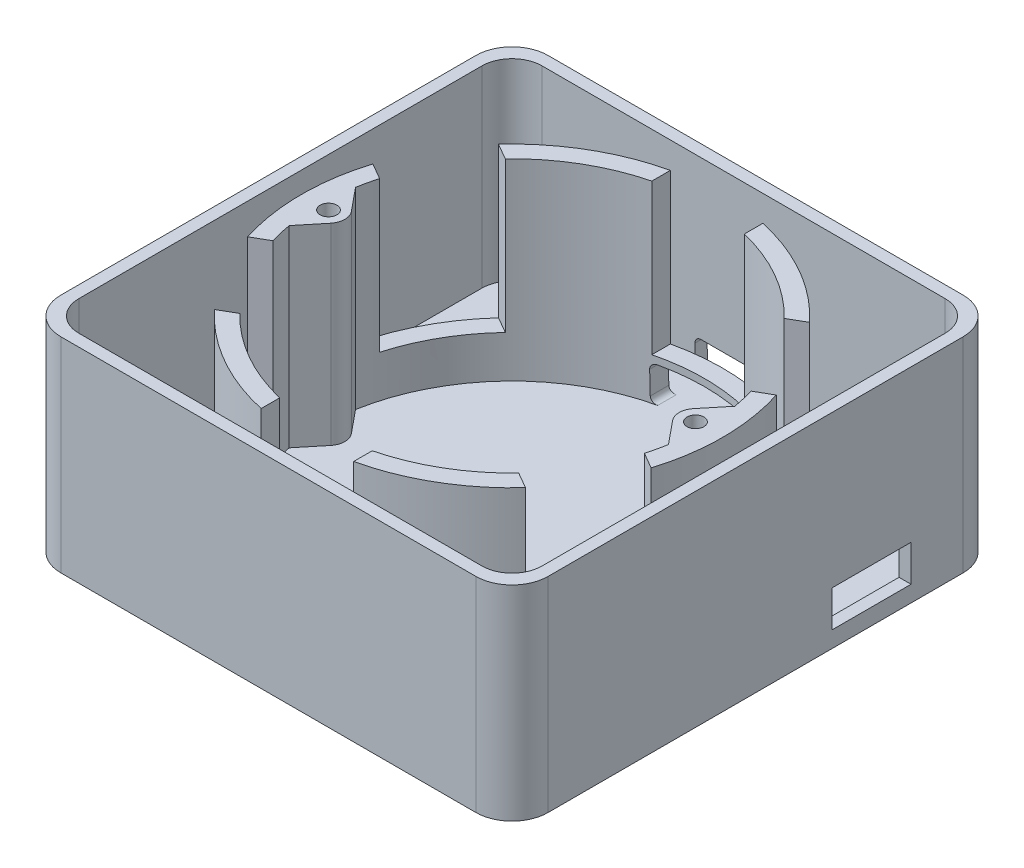
from build123d import *

# Parameters (mm, degrees)
BOSS_EXTRUDE1_DEPTH   = 32
SKETCH1_R             = 35
SKETCH1_R_2           = 1.4
BOSS_EXTRUDE1_2_DEPTH = 32
BOSS_EXTRUDE2_DEPTH   = 2
CUT_EXTRUDE2_DEPTH    = 21
SKETCH6_W             = 15.309854706
SKETCH6_H             = 5.844258332
CUT_EXTRUDE3_DEPTH    = 25
CUT_EXTRUDE4_DEPTH    = 10
SKETCH8_W             = 13.107410135
SKETCH8_H             = 6.042738895
CUT_EXTRUDE5_DEPTH    = 4


with BuildPart() as part:
    # Sketch1 → Boss-Extrude1 (new body)
    with BuildSketch(Plane(origin=(0, 0, 0), x_dir=(1, 0, 0), z_dir=(0, 1, 0))):
        with BuildLine():
            ThreePointArc((81, 75), (79.242640687, 79.242640687), (75, 81))
            Line((75, 81), (40.5, 81))
            Line((40.5, 81), (6, 81))
            ThreePointArc((6, 81), (1.757359313, 79.242640687), (0, 75))
            Line((0, 75), (0, 6))
            ThreePointArc((0, 6), (1.757359313, 1.757359313), (6, 0))
            Line((6, 0), (75, 0))
            ThreePointArc((75, 0), (79.242640687, 1.757359313), (81, 6))
            Line((81, 6), (81, 75))
        make_face()
        with BuildLine():
            Line((2, 7), (2, 74))
            ThreePointArc((2, 74), (3.464466094, 77.535533906), (7, 79))
            Line((7, 79), (74, 79))
            ThreePointArc((74, 79), (77.535533906, 77.535533906), (79, 74))
            Line((79, 74), (79, 7))
            ThreePointArc((79, 7), (77.535533906, 3.464466094), (74, 2))
            Line((74, 2), (7, 2))
            ThreePointArc((7, 2), (3.464466094, 3.464466094), (2, 7))
        make_face(mode=Mode.SUBTRACT)
    extrude(amount=BOSS_EXTRUDE1_DEPTH)



with BuildPart() as body_2:
    # Sketch1 → Boss-Extrude1 2 (new body)
    with BuildSketch(Plane(origin=(0, 0, 0), x_dir=(1, 0, 0), z_dir=(0, 1, 0))):
        with Locations((40.5, 40.5)):
            Circle(SKETCH1_R)
        with Locations((10, 40.5)):
            Circle(SKETCH1_R_2, mode=Mode.SUBTRACT)
        with BuildLine():
            Line((72.022034214, 46.010114245), (68.910941455, 42.210507058))
            ThreePointArc((68.910941455, 42.210507058), (68.3, 40.5), (68.910941455, 38.789492942))
            Line((68.910941455, 38.789492942), (72.022034214, 34.989885755))
            ThreePointArc((72.022034214, 34.989885755), (40.5, 8.5), (8.977965786, 34.989885755))
            Line((8.977965786, 34.989885755), (12.089058545, 38.789492942))
            ThreePointArc((12.089058545, 38.789492942), (12.7, 40.5), (12.089058545, 42.210507058))
            Line((12.089058545, 42.210507058), (8.977965786, 46.010114245))
            ThreePointArc((8.977965786, 46.010114245), (40.5, 72.5), (72.022034214, 46.010114245))
        make_face(mode=Mode.SUBTRACT)
        with Locations((71, 40.5)):
            Circle(SKETCH1_R_2, mode=Mode.SUBTRACT)
    extrude(amount=BOSS_EXTRUDE1_2_DEPTH)


with BuildPart() as part_1:
    add(part.part)

    add(body_2.part)  # Boss-Extrude2 merges body 2
    # Sketch2 → Boss-Extrude2 (add)
    with BuildSketch(Plane.XZ):
        with BuildLine():
            Line((6, 0), (75, 0))
            ThreePointArc((75, 0), (79.242640687, -1.757359313), (81, -6))
            Line((81, -6), (81, -75))
            ThreePointArc((81, -75), (79.242640687, -79.242640687), (75, -81))
            Line((75, -81), (6, -81))
            ThreePointArc((6, -81), (1.757359313, -79.242640687), (0, -75))
            Line((0, -75), (0, -6))
            ThreePointArc((0, -6), (1.757359313, -1.757359313), (6, 0))
        make_face()
    extrude(amount=BOSS_EXTRUDE2_DEPTH)

    # Sketch4 → Cut-Extrude2 (cut)
    with BuildSketch(Plane(origin=(0, 0, -81), x_dir=(-1, 0, 0), z_dir=(0, 0, -1))):
        with BuildLine():
            Line((-33.5, 0), (-47.5, 0))
            ThreePointArc((-47.5, 0), (-48.207106781, 0.292893219), (-48.5, 1))
            Line((-48.5, 1), (-48.5, 4.819564815))
            ThreePointArc((-48.5, 4.819564815), (-48.207106781, 5.526671596), (-47.5, 5.819564815))
            Line((-47.5, 5.819564815), (-33.420681037, 5.819564815))
            ThreePointArc((-33.420681037, 5.819564815), (-32.706271485, 5.519292613), (-32.42089659, 4.798802799))
            Line((-32.42089659, 4.798802799), (-32.500215554, 0.979237984))
            ThreePointArc((-32.500215554, 0.979237984), (-32.800272202, 0.285590448), (-33.5, 0))
        make_face()
    extrude(amount=-CUT_EXTRUDE2_DEPTH, mode=Mode.SUBTRACT)

    # Sketch6 → Cut-Extrude3 (cut)
    with BuildSketch(Plane(origin=(0, 32, 0), x_dir=(1, 0, 0), z_dir=(0, 1, 0))):
        Polygon((75.235639911, 51.874157904), (67.580712557, 65.132881008), (62.519436376, 62.210751842), (70.174363729, 48.952028738), align=None)
        with Locations((40.362582911, 73.346896365)):
            Rectangle(SKETCH6_W, SKETCH6_H)
        Polygon((67.718129646, 16.105132373), (75.373057, 29.363855477), (70.311780818, 32.285984643), (62.656853465, 19.027261539), align=None)
        with Locations((40.637417089, 7.653103635)):
            Rectangle(SKETCH6_W, SKETCH6_H)
        Polygon((5.764360089, 29.125842096), (13.419287443, 15.867118992), (18.480563624, 18.789248158), (10.825636271, 32.047971262), align=None)
        Polygon((13.281870354, 64.894867627), (5.626943, 51.636144523), (10.688219182, 48.714015357), (18.343146535, 61.972738461), align=None)
    extrude(amount=-CUT_EXTRUDE3_DEPTH, mode=Mode.SUBTRACT)

    # Sketch7 → Cut-Extrude4 (cut)
    with BuildSketch(Plane(origin=(0, -2, 0), x_dir=(-1, 0, 0), z_dir=(0, -1, 0))):
        with BuildLine():
            Line((-7.680011474, 71.616048913), (-7.680011474, 67.349875153))
            ThreePointArc((-7.680011474, 67.349875153), (-9.680011474, 65.349875153), (-11.680011474, 67.349875153))
            Line((-11.680011474, 67.349875153), (-11.680011474, 71.616048913))
            ThreePointArc((-11.680011474, 71.616048913), (-9.680011474, 73.616048913), (-7.680011474, 71.616048913))
        make_face()
        with BuildLine():
            Line((-73.319988526, 71.616048913), (-73.319988526, 67.349875153))
            ThreePointArc((-73.319988526, 67.349875153), (-71.319988526, 65.349875153), (-69.319988526, 67.349875153))
            Line((-69.319988526, 67.349875153), (-69.319988526, 71.616048913))
            ThreePointArc((-69.319988526, 71.616048913), (-71.319988526, 73.616048913), (-73.319988526, 71.616048913))
        make_face()
        with BuildLine():
            Line((-69.319988526, 9.383951087), (-69.319988526, 13.650124847))
            ThreePointArc((-69.319988526, 13.650124847), (-71.319988526, 15.650124847), (-73.319988526, 13.650124847))
            Line((-73.319988526, 13.650124847), (-73.319988526, 9.383951087))
            ThreePointArc((-73.319988526, 9.383951087), (-71.319988526, 7.383951087), (-69.319988526, 9.383951087))
        make_face()
        with BuildLine():
            Line((-11.680011474, 9.383951087), (-11.680011474, 13.650124847))
            ThreePointArc((-11.680011474, 13.650124847), (-9.680011474, 15.650124847), (-7.680011474, 13.650124847))
            Line((-7.680011474, 13.650124847), (-7.680011474, 9.383951087))
            ThreePointArc((-7.680011474, 9.383951087), (-9.680011474, 7.383951087), (-11.680011474, 9.383951087))
        make_face()
    extrude(amount=-CUT_EXTRUDE4_DEPTH, mode=Mode.SUBTRACT)

    # Sketch8 → Cut-Extrude5 (cut)
    with BuildSketch(Plane(origin=(81, 0, 0), x_dir=(0, 0, -1), z_dir=(1, 0, 0))):
        with Locations((59.784555183, 3.719478255)):
            Rectangle(SKETCH8_W, SKETCH8_H)
    extrude(amount=-CUT_EXTRUDE5_DEPTH, mode=Mode.SUBTRACT)


solid = part_1.part
